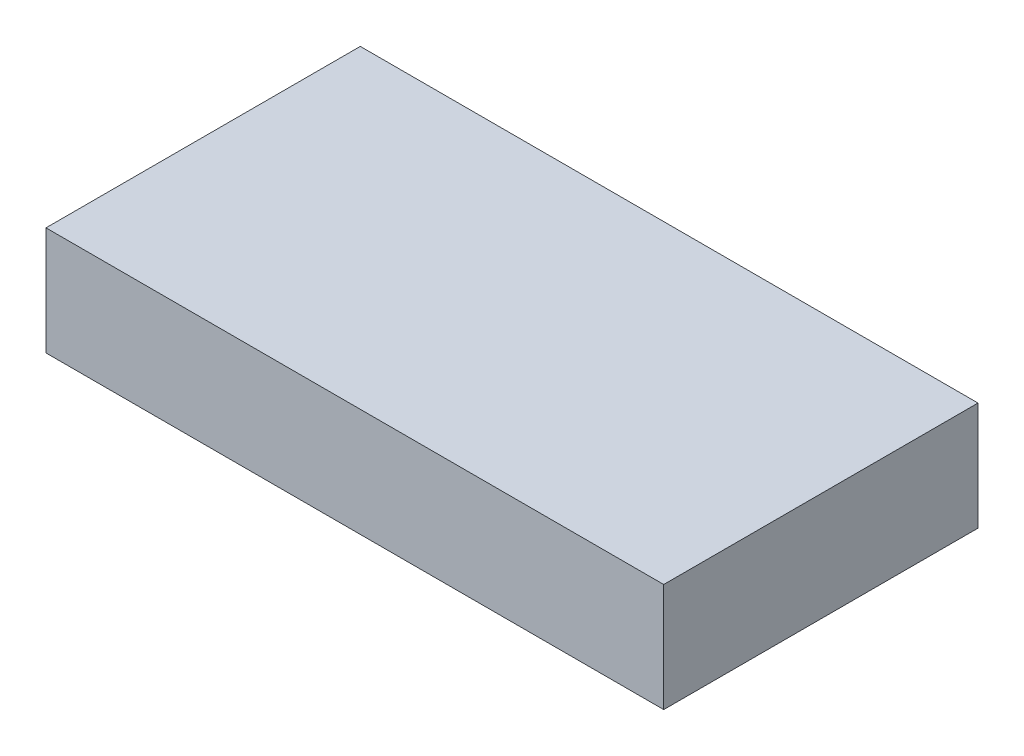
from build123d import *

# Parameters (mm, degrees)
SKETCH1_W           = 57
SKETCH1_H           = 29
BOSS_EXTRUDE1_DEPTH = 10


with BuildPart() as part:
    # Sketch1 → Boss-Extrude1 (new body)
    with BuildSketch(Plane(origin=(0, 0, 0), x_dir=(1, 0, 0), z_dir=(0, 1, 0))):
        with Locations((28.5, 14.5)):
            Rectangle(SKETCH1_W, SKETCH1_H)
    extrude(amount=BOSS_EXTRUDE1_DEPTH)


solid = part.part
